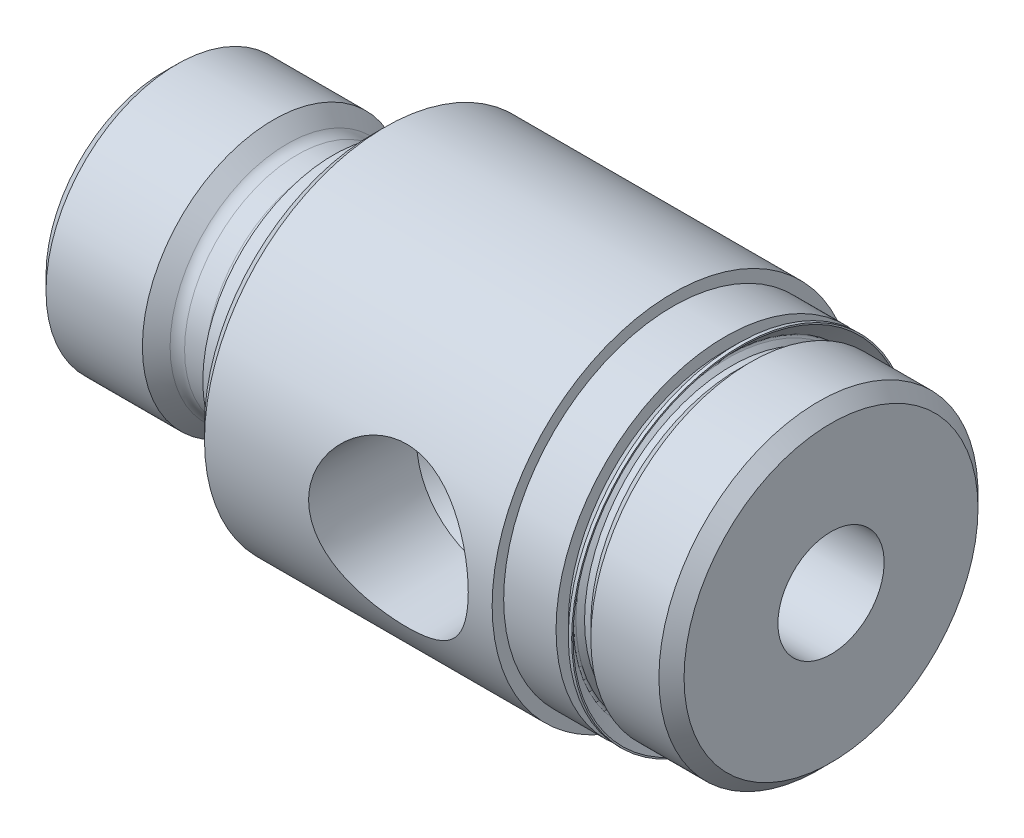
from build123d import *

# Parameters (mm, degrees)
SKETCH4_W = 3.175
SKETCH4_H = 5.08


with BuildPart() as part:
    # Sketch1 → Revolve1 (revolve)
    with BuildSketch(Plane.XY):
        with BuildLine():
            Line((0, 0), (0, 7.09803))
            Line((0, 7.09803), (0.83947, 7.9375))
            Line((0.83947, 7.9375), (6.681592328, 7.9375))
            Line((6.681592328, 7.9375), (7.520171502, 7.096504435))
            ThreePointArc((7.520171502, 7.096504435), (7.804772216, 6.905895804), (8.1407, 6.83895))
            Line((8.1407, 6.83895), (9.4361, 6.83895))
            ThreePointArc((9.4361, 6.83895), (10.055737672, 7.095612328), (10.3124, 7.71525))
            Line((10.3124, 7.71525), (10.3124, 7.90575))
            Line((10.3124, 7.90575), (12.7, 7.90575))
            Line((12.7, 7.90575), (12.7, 0))
            Line((12.7, 0), (0, 0))
        make_face()
    revolve(axis=Axis((12.7, 0, 0), (-1, 0, 0)))

    # Sketch2 → Revolve2 (revolve)
    with BuildSketch(Plane.XY):
        Polygon((12.7, 0), (12.7, 10.19175), (13.462, 10.95375), (34.0741, 10.95375), (34.0741, 8.90905), (34.8361, 8.90905), (35.5981, 9.67105), (39.7256, 9.67105), (40.4876, 8.90905), (40.4876, 0), align=None)
    revolve(axis=Axis((40.4876, 0, 0), (-1, 0, 0)))

    # Sketch3 → Cut-Revolve1 (revolve, cut)
    with BuildSketch(Plane.XY):
        Polygon((0, 0), (0, 3.47345), (0.254, 3.21945), (40.4876, 3.21945), (40.4876, 0), align=None)
    revolve(axis=Axis((40.4876, 0, 0), (-1, 0, 0)), mode=Mode.SUBTRACT)

    # Sketch4 → Cut-Revolve2 (revolve, cut)
    with BuildSketch(Plane.XY):
        with Locations((32.4866, 12.79525)):
            Rectangle(SKETCH4_W, SKETCH4_H)
    revolve(axis=Axis((34.0741, 0, 0), (-1, 0, 0)), mode=Mode.SUBTRACT)

    # Sketch5 → Cut-Revolve3 (revolve, cut)
    with BuildSketch(Plane(origin=(0, 0, 0), x_dir=(1, 0, 0), z_dir=(0, 1, 0))):
        Polygon((24.6126, 0), (27.7876, 0), (27.7876, -3.137518166), (29.253831834, -4.60375), (29.452075925, -10.95375), (24.6126, -10.95375), align=None)
    revolve(axis=Axis((24.6126, 0, 10.95375), (0, 0, -1)), mode=Mode.SUBTRACT)

    # Sketch6 → Revolve3 (revolve)
    with BuildSketch(Plane.XY):
        with BuildLine():
            Line((34.0741, 9.51204893), (34.0741, 8.65505))
            Line((34.0741, 8.65505), (34.8361, 8.65505))
            Line((34.8361, 8.65505), (34.8361, 8.90905))
            Line((34.8361, 8.90905), (34.4551, 8.90905))
            Line((34.4551, 8.90905), (34.196587194, 9.167562806))
            ThreePointArc((34.196587194, 9.167562806), (34.159389755, 9.257365367), (34.196587194, 9.347167928))
            Line((34.196587194, 9.347167928), (35.02050107, 10.171081804))
            Line((35.02050107, 10.171081804), (35.02050107, 10.25525))
            Line((35.02050107, 10.25525), (34.81730107, 10.25525))
            Line((34.81730107, 10.25525), (34.0741, 9.51204893))
        make_face()
    revolve(axis=Axis((34.8361, 0, 0), (-1, 0, 0)))


solid = part.part
